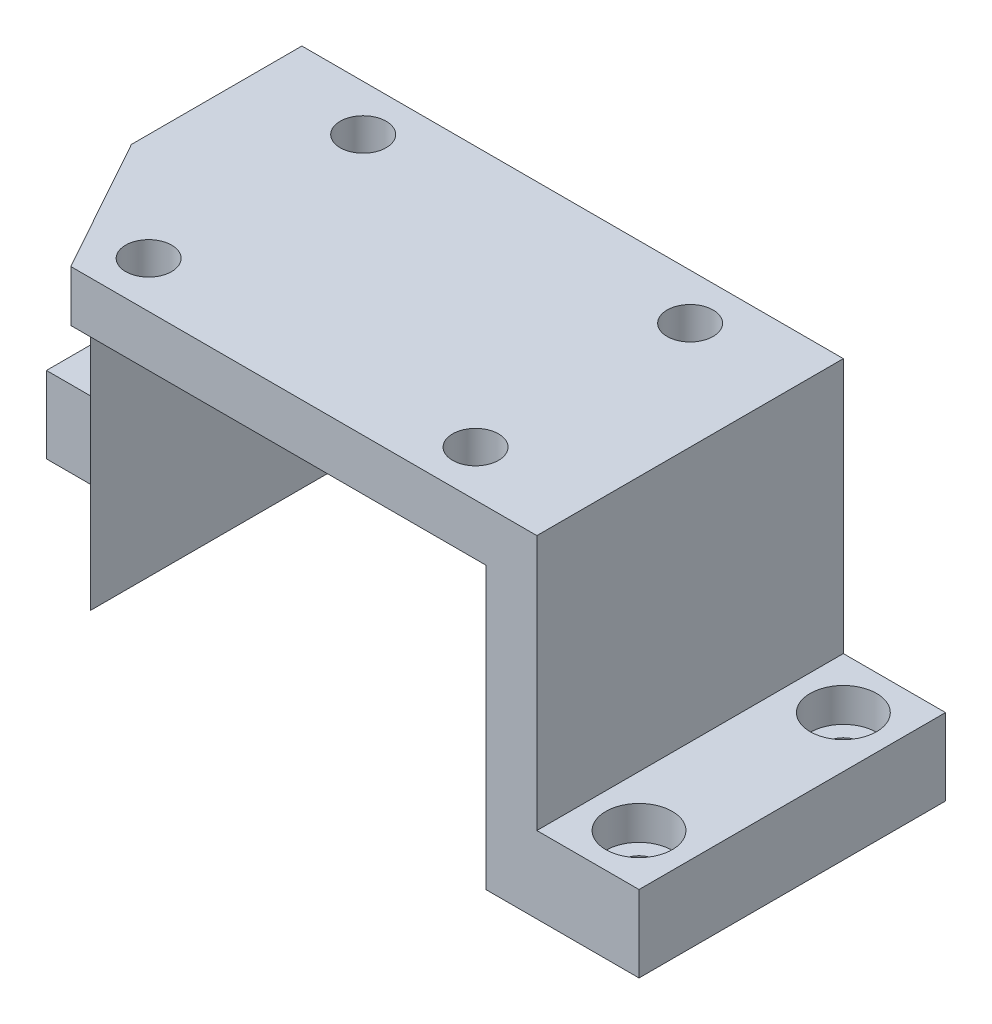
from build123d import *

# Parameters (mm, degrees)
SKETCH1_W           = 106
SKETCH1_H           = 60
BOSS_EXTRUDE1_DEPTH = 10
SKETCH2_W           = 10
SKETCH2_H           = 60
BOSS_EXTRUDE2_DEPTH = 55
SKETCH3_W           = 60
SKETCH3_H           = 15
BOSS_EXTRUDE3_DEPTH = 20
SKETCH4_W           = 30
SKETCH4_H           = 15
BOSS_EXTRUDE4_DEPTH = 20
SKETCH5_R           = 4.5
CUT_EXTRUDE1_DEPTH  = 66
SKETCH6_R           = 6.5
CUT_EXTRUDE2_DEPTH  = 6.6
SKETCH7_R           = 3.3
CUT_EXTRUDE3_DEPTH  = 9.4
CUT_EXTRUDE4_DEPTH  = 66


with BuildPart() as part:
    # Sketch1 → Boss-Extrude1 (new body)
    with BuildSketch(Plane(origin=(0, 0, 0), x_dir=(1, 0, 0), z_dir=(0, 1, 0))):
        Rectangle(SKETCH1_W, SKETCH1_H)
    extrude(amount=BOSS_EXTRUDE1_DEPTH)

    # Sketch2 → Boss-Extrude2 (add)
    with BuildSketch(Plane.XZ):
        with Locations((-48, 0)):
            Rectangle(SKETCH2_W, SKETCH2_H)
        with Locations((48, 0)):
            Rectangle(SKETCH2_W, SKETCH2_H)
    extrude(amount=BOSS_EXTRUDE2_DEPTH)

    # Sketch3 → Boss-Extrude3 (add)
    with BuildSketch(Plane(origin=(53, 0, 0), x_dir=(0, 0, -1), z_dir=(1, 0, 0))):
        with Locations((0, -47.5)):
            Rectangle(SKETCH3_W, SKETCH3_H)
    extrude(amount=BOSS_EXTRUDE3_DEPTH)

    # Sketch4 → Boss-Extrude4 (add)
    with BuildSketch(Plane.ZY.offset(53)):
        with Locations((-15, -47.5)):
            Rectangle(SKETCH4_W, SKETCH4_H)
    extrude(amount=BOSS_EXTRUDE4_DEPTH)

    # Sketch5 → Cut-Extrude1 (cut, through all)
    with BuildSketch(Plane(origin=(0, 10, 0), x_dir=(1, 0, 0), z_dir=(0, 1, 0))):
        with Locations((-32, 21)):
            Circle(SKETCH5_R)
        with Locations((32, 21)):
            Circle(SKETCH5_R)
        with Locations((32, -21)):
            Circle(SKETCH5_R)
        with Locations((-32, -21)):
            Circle(SKETCH5_R)
    extrude(amount=-CUT_EXTRUDE1_DEPTH, mode=Mode.SUBTRACT)

    # Sketch6 → Cut-Extrude2 (cut)
    with BuildSketch(Plane(origin=(0, -40, 0), x_dir=(1, 0, 0), z_dir=(0, 1, 0))):
        with Locations((63, 20)):
            Circle(SKETCH6_R)
        with Locations((63, -20)):
            Circle(SKETCH6_R)
        with Locations((-63, 20)):
            Circle(SKETCH6_R)
    extrude(amount=-CUT_EXTRUDE2_DEPTH, mode=Mode.SUBTRACT)

    # Sketch7 → Cut-Extrude3 (cut, through all)
    with BuildSketch(Plane(origin=(0, -46.6, 0), x_dir=(1, 0, 0), z_dir=(0, 1, 0))):
        with Locations((-63, 20)):
            Circle(SKETCH7_R)
        with Locations((63, -20)):
            Circle(SKETCH7_R)
        with Locations((63, 20)):
            Circle(SKETCH7_R)
    extrude(amount=-CUT_EXTRUDE3_DEPTH, mode=Mode.SUBTRACT)

    # Sketch8 → Cut-Extrude4 (cut, through all)
    with BuildSketch(Plane(origin=(0, 10, 0), x_dir=(1, 0, 0), z_dir=(0, 1, 0))):
        Polygon((-38.239, -30), (-53, -3.370451084), (-53, -30), align=None)
    extrude(amount=-CUT_EXTRUDE4_DEPTH, mode=Mode.SUBTRACT)


solid = part.part
